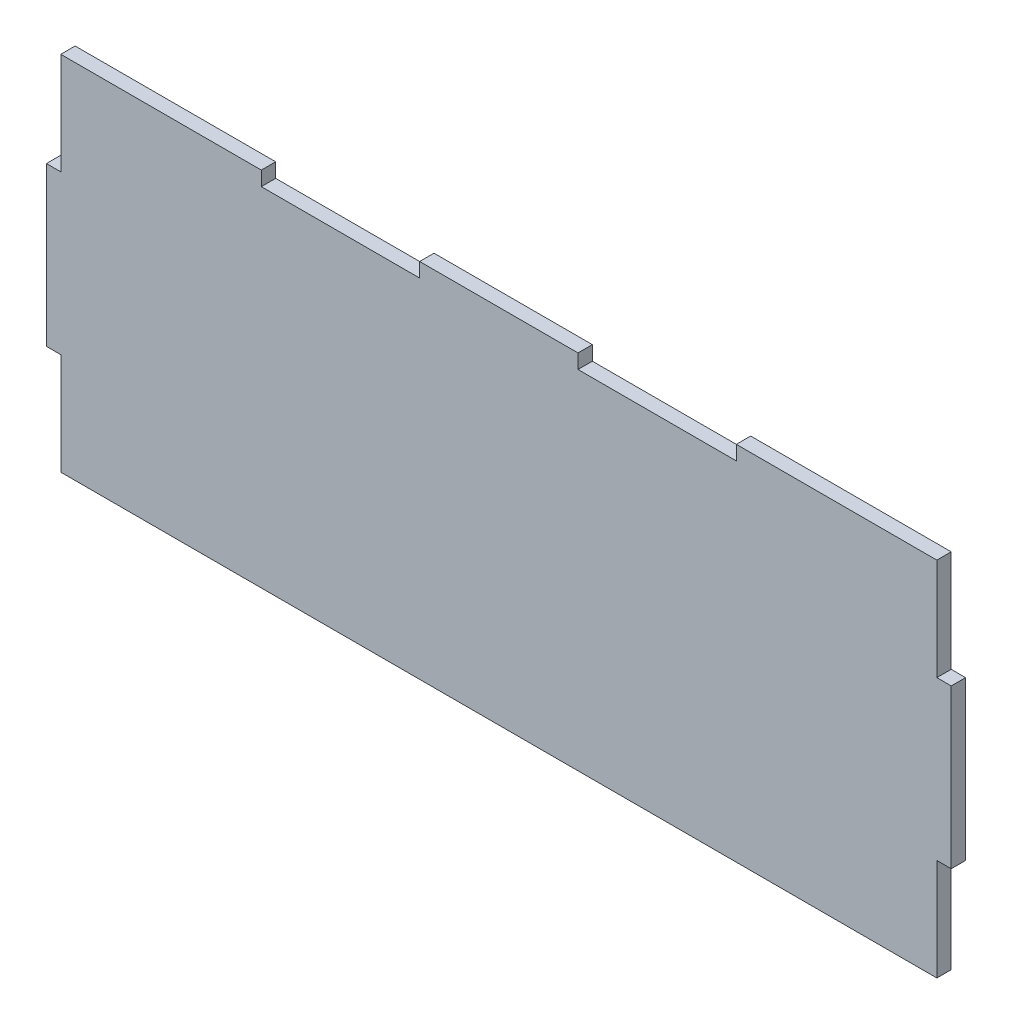
from build123d import *

# Parameters (mm, degrees)
ESQUISSE2_W             = 200
ESQUISSE2_H             = 80
BOSS_EXTRU_1_DEPTH      = 3.175
ESQUISSE3_W             = 35
ESQUISSE3_H             = 3.175
ENL_V_MAT_EXTRU_1_DEPTH = 4.175
ESQUISSE4_W             = 3.175
ESQUISSE4_H             = 22.5
ENL_V_MAT_EXTRU_2_DEPTH = 4.175


with BuildPart() as part:
    # Esquisse2 → Boss.-Extru.1 (new body)
    with BuildSketch(Plane.XY):
        Rectangle(ESQUISSE2_W, ESQUISSE2_H)
    extrude(amount=BOSS_EXTRU_1_DEPTH)

    # Esquisse3 → Enlèv. mat.-Extru.1 (cut, through all)
    with BuildSketch(Plane.XY.offset(3.175)):
        with Locations((35, 38.4125)):
            Rectangle(ESQUISSE3_W, ESQUISSE3_H)
        with Locations((-35, 38.4125)):
            Rectangle(ESQUISSE3_W, ESQUISSE3_H)
    extrude(amount=-ENL_V_MAT_EXTRU_1_DEPTH, mode=Mode.SUBTRACT)

    # Esquisse4 → Enlèv. mat.-Extru.2 (cut, through all)
    with BuildSketch(Plane.XY.offset(3.175)):
        with Locations((-98.4125, 28.75)):
            Rectangle(ESQUISSE4_W, ESQUISSE4_H)
        with Locations((-98.4125, -28.75)):
            Rectangle(ESQUISSE4_W, ESQUISSE4_H)
    enl_v_mat_extru_2 = extrude(amount=-ENL_V_MAT_EXTRU_2_DEPTH, mode=Mode.SUBTRACT)

    # Symétrie1: Enlèv. mat.-Extru.2 across plane
    add(enl_v_mat_extru_2.mirror(Plane(origin=(0, 0, 0), x_dir=(0, 0, 1), z_dir=(1, 0, 0))), mode=Mode.SUBTRACT)


solid = part.part
